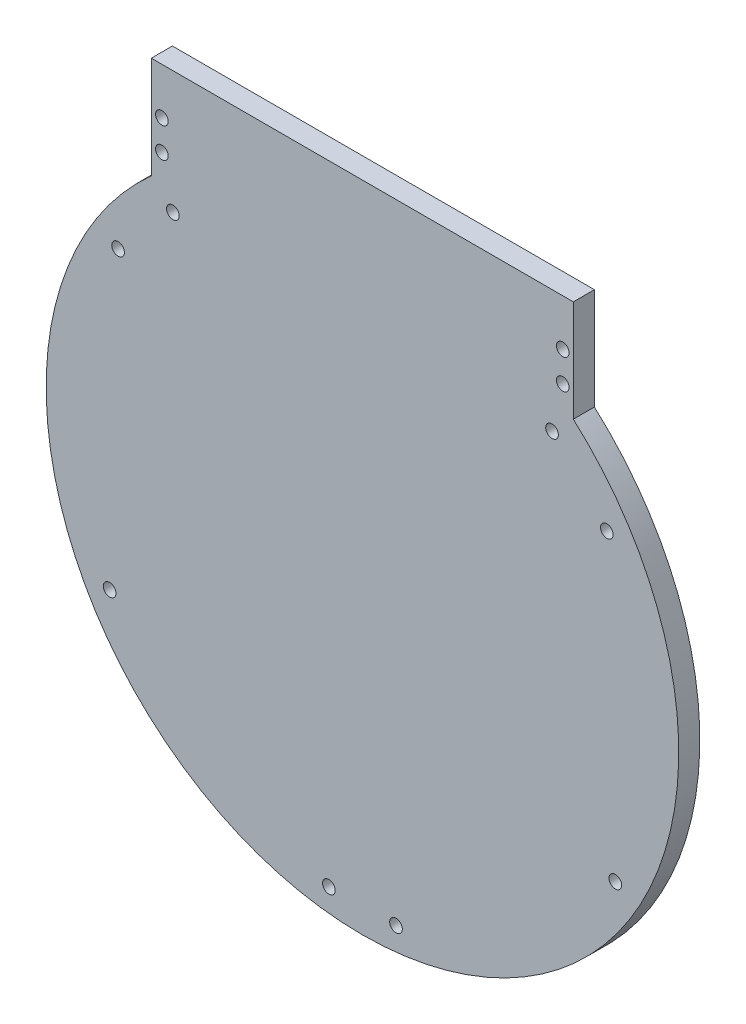
from build123d import *

# Parameters (mm, degrees)
RESSALTO_EXTRUS_O1_DEPTH = 5
ESBO_O2_R                = 1.5
CORTE_EXTRUS_O1_DEPTH    = 10
ESBO_O3_R                = 1.5
CORTE_EXTRUS_O2_DEPTH    = 6


with BuildPart() as part:
    # Esboço1 → Ressalto-extrusão1 (new body)
    with BuildSketch(Plane.XY):
        with BuildLine():
            Line((44.495405461, -168.430491325), (44.495405461, -144.332190763))
            Line((44.495405461, -144.332190763), (-55.573351401, -144.332190763))
            Line((-55.573351401, -144.332190763), (-55.573351401, -168.393072388))
            Line((-55.573351401, -168.393072388), (-55.504594539, -168.430491325))
            ThreePointArc((-55.504594539, -168.430491325), (-5.504594539, -299.332190763), (44.495405461, -168.430491325))
        make_face()
    extrude(amount=RESSALTO_EXTRUS_O1_DEPTH)

    # Esboço2 → Corte-extrusão1 (cut)
    with BuildSketch(Plane.XY.offset(5)):
        with Locations((39.44625518, -173.430491325)):
            Circle(ESBO_O2_R)
        with Locations((52.44625518, -187.430491325)):
            Circle(ESBO_O2_R)
        with Locations((54.44625518, -258.430491325)):
            Circle(ESBO_O2_R)
        with Locations((-13.455444258, -293.430491325)):
            Circle(ESBO_O2_R)
        with Locations((2.44625518, -293.430491325)):
            Circle(ESBO_O2_R)
        with Locations((-65.455444258, -258.430491325)):
            Circle(ESBO_O2_R)
        with Locations((-63.455444258, -187.430491325)):
            Circle(ESBO_O2_R)
        with Locations((-50.455444258, -173.430491325)):
            Circle(ESBO_O2_R)
    extrude(amount=-CORTE_EXTRUS_O1_DEPTH, mode=Mode.SUBTRACT)

    # Esboço3 → Corte-extrusão2 (cut, through all)
    with BuildSketch(Plane.XY.offset(5)):
        with Locations((-53.073351401, -162.430491325)):
            Circle(ESBO_O3_R)
        with Locations((-53.073351401, -155.332190763)):
            Circle(ESBO_O3_R)
        with Locations((41.995405461, -162.430491325)):
            Circle(ESBO_O3_R)
        with Locations((41.995405461, -155.332190763)):
            Circle(ESBO_O3_R)
    extrude(amount=-CORTE_EXTRUS_O2_DEPTH, mode=Mode.SUBTRACT)


solid = part.part
